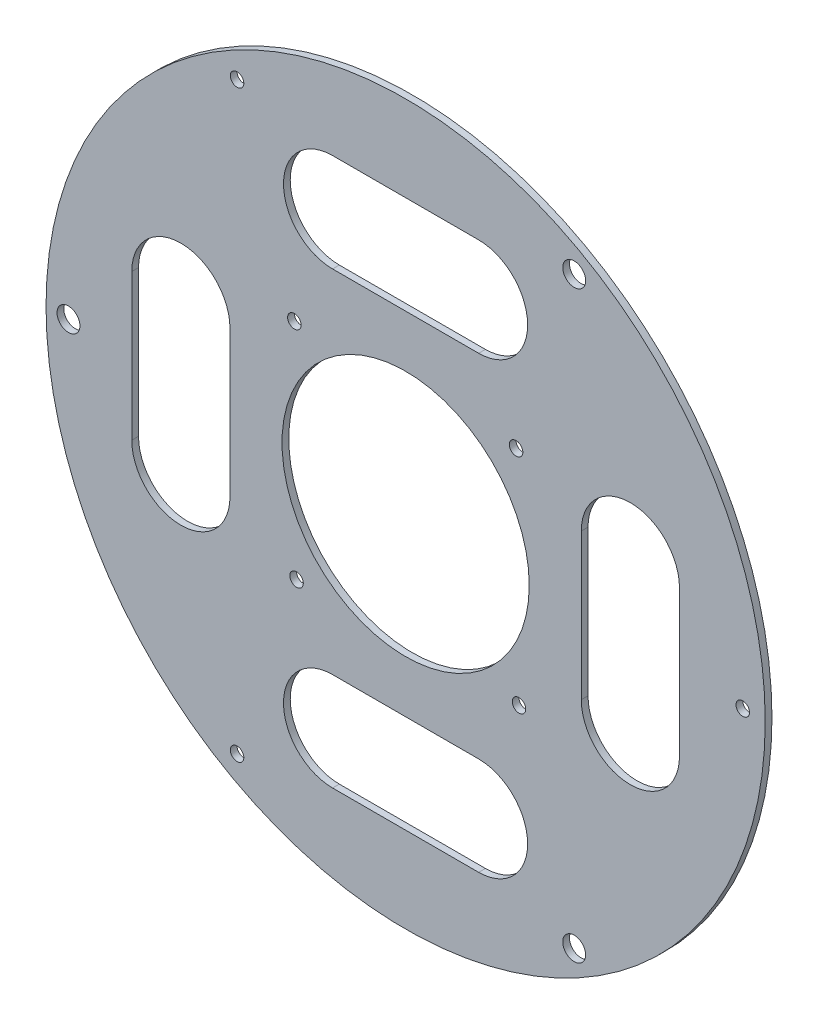
from build123d import *

# Parameters (mm, degrees)
CROQUIS1_R              = 160
CROQUIS1_R_2            = 55
CROQUIS1_R_3            = 5.1
CROQUIS1_R_4            = 3
SALIENTE_EXTRUIR2_DEPTH = 3


with BuildPart() as part:
    # Croquis1 → Saliente-Extruir2 (new body)
    with BuildSketch(Plane.XY):
        Circle(CROQUIS1_R)
        Circle(CROQUIS1_R_2, mode=Mode.SUBTRACT)
        with Locations((-150, 0)):
            Circle(CROQUIS1_R_3, mode=Mode.SUBTRACT)
        with Locations((-48.532730183, -49.522943911)):
            Circle(CROQUIS1_R_4, mode=Mode.SUBTRACT)
        with Locations((75, 129.903810568)):
            Circle(CROQUIS1_R_3, mode=Mode.SUBTRACT)
        with Locations((75, -129.903810568)):
            Circle(CROQUIS1_R_3, mode=Mode.SUBTRACT)
        with Locations((-75, 129.903810568)):
            Circle(CROQUIS1_R_4, mode=Mode.SUBTRACT)
        with Locations((150, 0)):
            Circle(CROQUIS1_R_4, mode=Mode.SUBTRACT)
        with Locations((-75, -129.903810568)):
            Circle(CROQUIS1_R_4, mode=Mode.SUBTRACT)
        with Locations((-49.499768998, 49.495180262)):
            Circle(CROQUIS1_R_4, mode=Mode.SUBTRACT)
        with Locations((50.43565577, -48.541164253)):
            Circle(CROQUIS1_R_4, mode=Mode.SUBTRACT)
        with Locations((49.144383708, 49.848064656)):
            Circle(CROQUIS1_R_4, mode=Mode.SUBTRACT)
        with BuildLine():
            Line((-32.5, 78.157247055), (32.5, 78.157247055))
            ThreePointArc((32.5, 78.157247055), (54.279441944, 100), (32.5, 121.842752945))
            Line((32.5, 121.842752945), (-32.5, 121.842752945))
            ThreePointArc((-32.5, 121.842752945), (-54.342752945, 100), (-32.5, 78.157247055))
        make_face(mode=Mode.SUBTRACT)
        with BuildLine():
            Line((-32.5, -121.842752945), (32.5, -121.842752945))
            ThreePointArc((32.5, -121.842752945), (54.279441944, -100), (32.5, -78.157247055))
            Line((32.5, -78.157247055), (-32.5, -78.157247055))
            ThreePointArc((-32.5, -78.157247055), (-54.342752945, -100), (-32.5, -121.842752945))
        make_face(mode=Mode.SUBTRACT)
        with BuildLine():
            Line((78.157247055, 32.5), (78.157247055, -32.5))
            ThreePointArc((78.157247055, -32.5), (100, -54.342752945), (121.842752945, -32.5))
            Line((121.842752945, -32.5), (121.842752945, 32.5))
            ThreePointArc((121.842752945, 32.5), (100, 54.342752945), (78.157247055, 32.5))
        make_face(mode=Mode.SUBTRACT)
        with BuildLine():
            Line((-78.157247055, 32.5), (-78.157247055, -32.5))
            ThreePointArc((-78.157247055, -32.5), (-100, -54.342752945), (-121.842752945, -32.5))
            Line((-121.842752945, -32.5), (-121.842752945, 32.5))
            ThreePointArc((-121.842752945, 32.5), (-100, 54.342752945), (-78.157247055, 32.5))
        make_face(mode=Mode.SUBTRACT)
    extrude(amount=SALIENTE_EXTRUIR2_DEPTH)


solid = part.part
